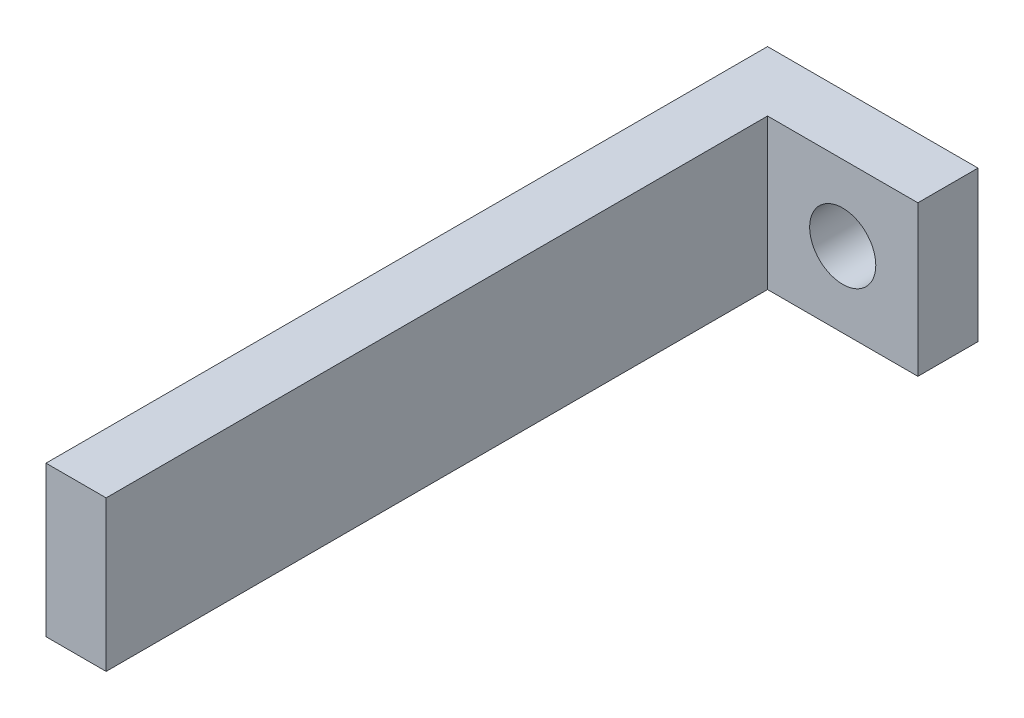
from build123d import *

# Parameters (mm, degrees)
SKETCH_1_W          = 25
SKETCH_1_H          = 25
EXTRUDE_1_DEPTH     = 10
SKETCH_2_W          = 10
SKETCH_2_H          = 25
EXTRUDE_2_DEPTH     = 120
SKETCH_6_R          = 5.5
CUT_EXTRUDE_1_DEPTH = 121


with BuildPart() as part:
    # ｽｹｯﾁ1 → ﾎﾞｽ - 押し出し1 (new body)
    with BuildSketch(Plane.XY):
        with Locations((-26.305611861, 22.91927309)):
            Rectangle(SKETCH_1_W, SKETCH_1_H)
    extrude(amount=EXTRUDE_1_DEPTH)

    # ｽｹｯﾁ2 → ﾎﾞｽ - 押し出し2 (add)
    with BuildSketch(Plane(origin=(0, 0, 0), x_dir=(-1, 0, 0), z_dir=(0, 0, -1))):
        with Locations((43.805611861, 22.91927309)):
            Rectangle(SKETCH_2_W, SKETCH_2_H)
    extrude(amount=-EXTRUDE_2_DEPTH)

    # ｽｹｯﾁ6 → ｶｯﾄ - 押し出し1 (cut, through all)
    with BuildSketch(Plane(origin=(0, 0, 0), x_dir=(-1, 0, 0), z_dir=(0, 0, -1))):
        with Locations((26.305611861, 22.91927309)):
            Circle(SKETCH_6_R)
    extrude(amount=-CUT_EXTRUDE_1_DEPTH, mode=Mode.SUBTRACT)


solid = part.part
